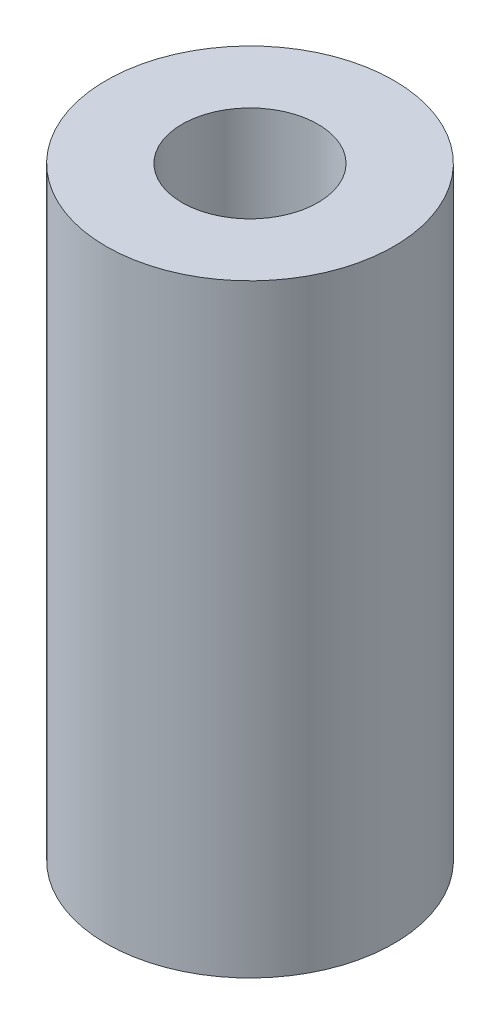
from build123d import *

# Parameters (mm, degrees)
SKETCH1_R           = 4.55
SKETCH1_R_2         = 2.15
BOSS_EXTRUDE2_DEPTH = 19.1


with BuildPart() as part:
    # Sketch1 → Boss-Extrude2 (new body)
    with BuildSketch(Plane(origin=(0, 0, 0), x_dir=(1, 0, 0), z_dir=(0, 1, 0))):
        Circle(SKETCH1_R)
        Circle(SKETCH1_R_2, mode=Mode.SUBTRACT)
    extrude(amount=BOSS_EXTRUDE2_DEPTH)


solid = part.part
